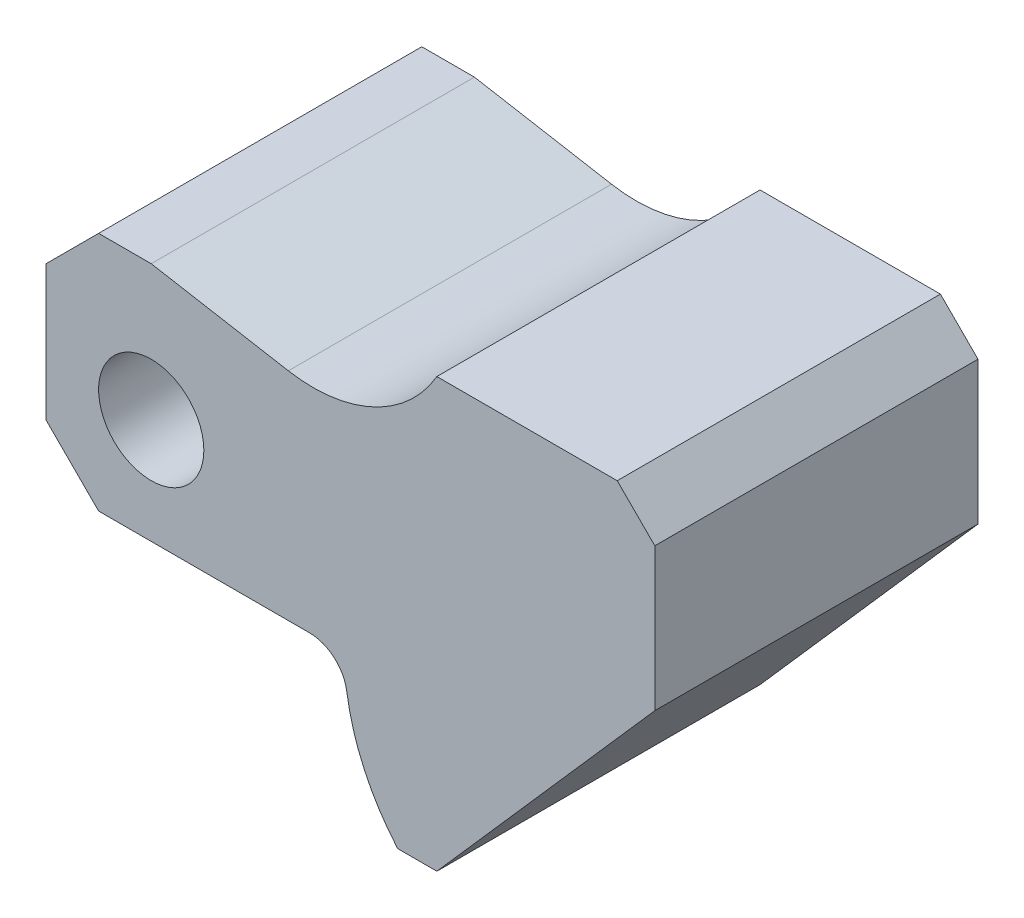
from build123d import *

# Parameters (mm, degrees)
SKETCH1_R           = 7
BOSS_EXTRUDE1_DEPTH = 43
CHAMFER1_SIZE       = 7
CHAMFER2_SIZE       = 7
CHAMFER3_SIZE       = 5
FILLET1_R           = 5


with BuildPart() as part:
    # Sketch1 → Boss-Extrude1 (new body)
    with BuildSketch(Plane.XY):
        with BuildLine():
            Line((14, 0), (0, 0))
            Line((0, 0), (0, -32))
            Line((0, -32), (39.698321338, -32))
            ThreePointArc((39.698321338, -32), (41.528870011, -42.140064899), (46.789418898, -51))
            Line((46.789418898, -51), (52.00318703, -51))
            Line((52.00318703, -51), (81, -18))
            Line((81, -18), (81, 6))
            Line((81, 6), (52, 6))
            ThreePointArc((52, 6), (43.574972961, -1.723930849), (32.243084988, -3.216748095))
            Line((32.243084988, -3.216748095), (14, 0))
        make_face()
        with Locations((14, -18)):
            Circle(SKETCH1_R, mode=Mode.SUBTRACT)
    extrude(amount=BOSS_EXTRUDE1_DEPTH)

    # Chamfer1
    chamfer1_edges = [part.edges().sort_by_distance(p)[0] for p in [
        (0, 0, 21.5),
    ]]
    chamfer(chamfer1_edges, length=CHAMFER1_SIZE)

    # Chamfer2
    chamfer2_edges = [part.edges().sort_by_distance(p)[0] for p in [
        (0, -32, 21.5),
    ]]
    chamfer(chamfer2_edges, length=CHAMFER2_SIZE)

    # Chamfer3
    chamfer3_edges = [part.edges().sort_by_distance(p)[0] for p in [
        (81, 6, 21.5),
    ]]
    chamfer(chamfer3_edges, length=CHAMFER3_SIZE)

    # Fillet1
    fillet1_edges = [part.edges().sort_by_distance(p)[0] for p in [
        (39.698321338, -32, 21.5),
    ]]
    fillet(fillet1_edges, radius=FILLET1_R)


solid = part.part
